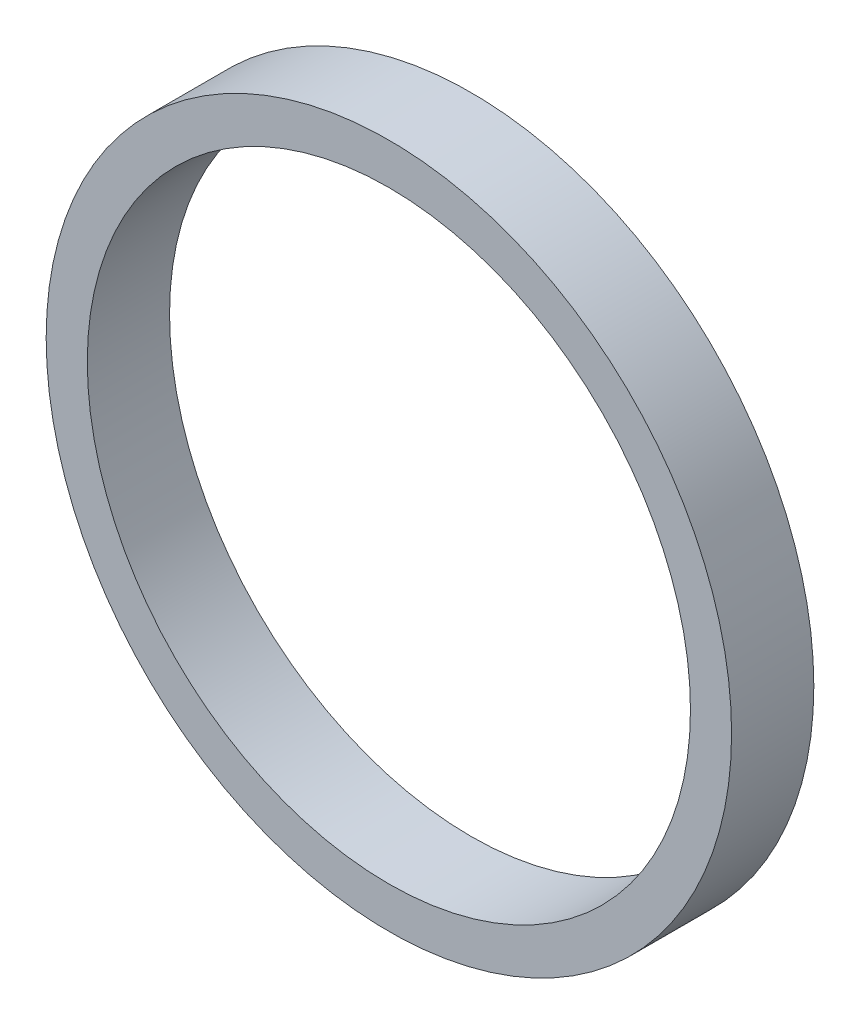
from build123d import *

# Parameters (mm, degrees)
SKETCH1_R           = 6.25
SKETCH1_R_2         = 5.5
BOSS_EXTRUDE1_DEPTH = 1.5


with BuildPart() as part:
    # Sketch1 → Boss-Extrude1 (new body)
    with BuildSketch(Plane.XY):
        Circle(SKETCH1_R)
        Circle(SKETCH1_R_2, mode=Mode.SUBTRACT)
    extrude(amount=BOSS_EXTRUDE1_DEPTH)


solid = part.part
